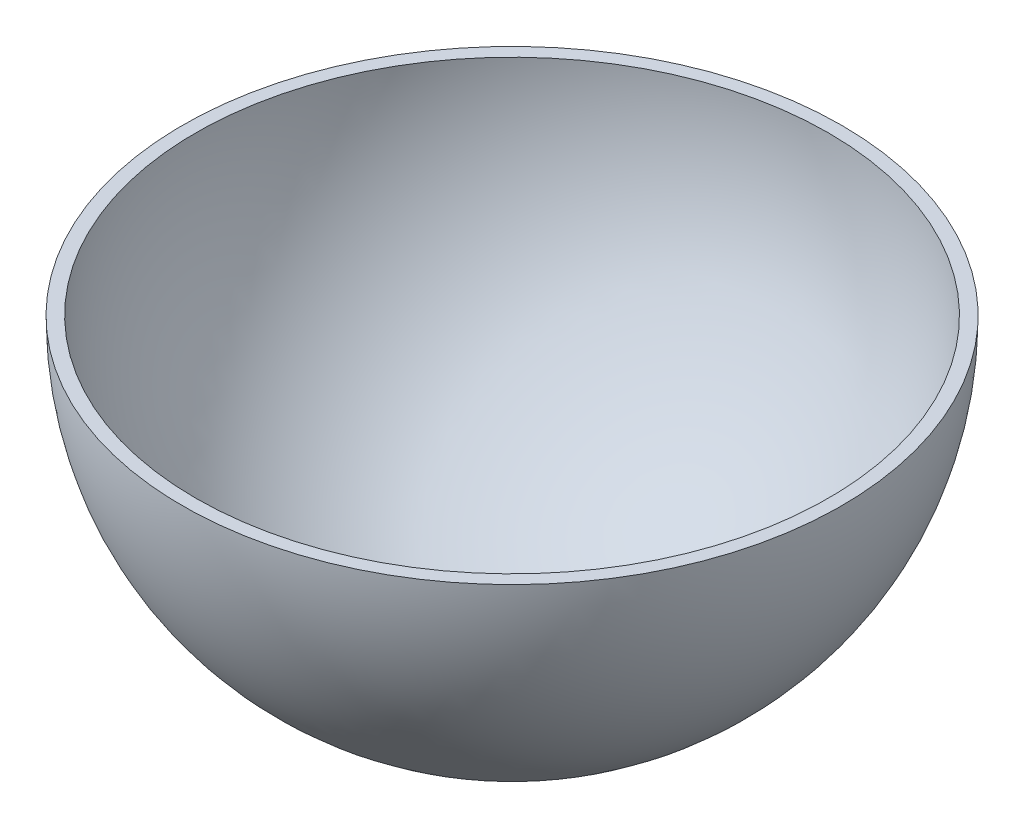
from build123d import *

# Parameters (mm, degrees)
THICKEN_1_T2 = 5


with BuildPart() as body_1:
    # Sheet Revolve 1: a surface, the sketch's curves turned about an axis
    with BuildLine(Plane.XY, mode=Mode.PRIVATE) as sheet_revolve_1_1_path:
        Line((0, 0), (35, 0))
        ThreePointArc((35, 0), (96.43650761, 43.368118547), (120, 114.782402832))
    sheet_revolve_1_1 = Shell.revolve(sheet_revolve_1_1_path.wire(), 360, Axis((0, 0, 0), (0, -1, 0)))
    add(Solid.thicken(sheet_revolve_1_1, -THICKEN_1_T2))


solid = body_1.part
